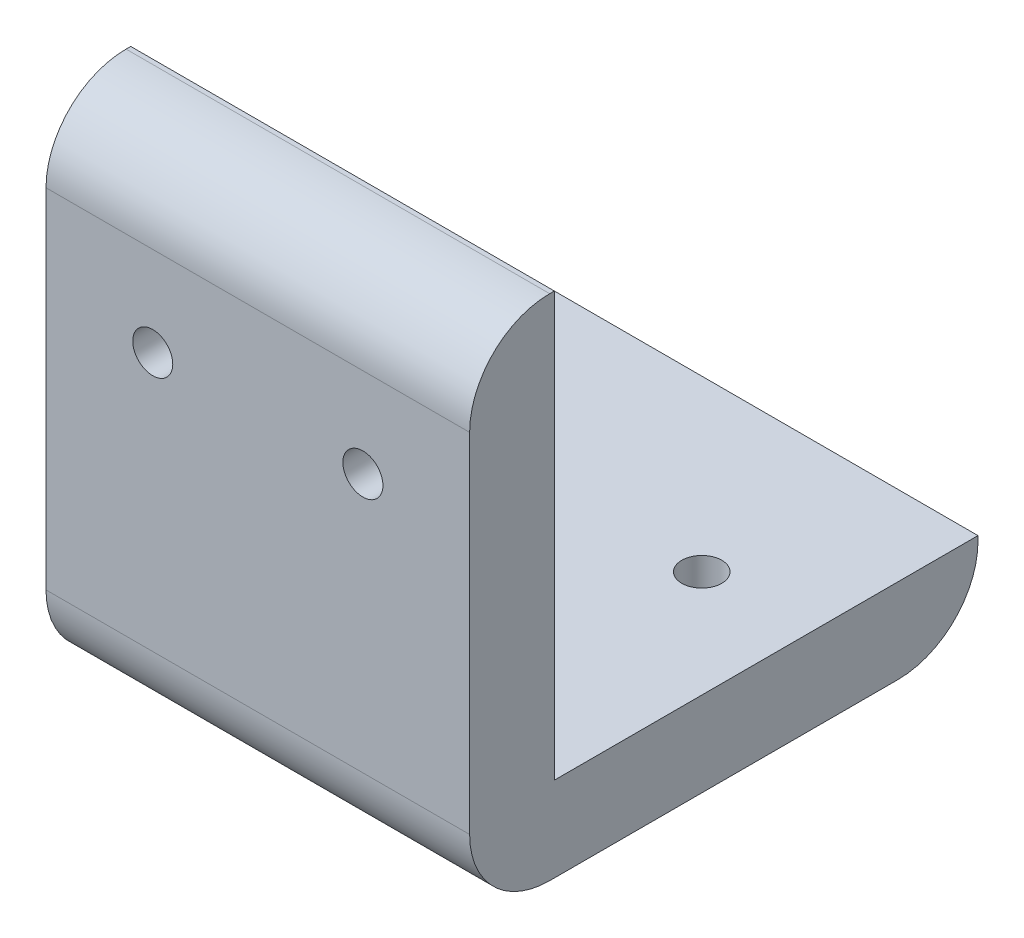
from build123d import *

# Parameters (mm, degrees)
BOSS_EXTRUDE1_DEPTH = 31.75
FILLET1_R           = 6
SKETCH2_R           = 1.5
CUT_EXTRUDE1_DEPTH  = 39.1
SKETCH3_R           = 1.5
CUT_EXTRUDE2_DEPTH  = 39.1
FILLET2_R           = 6


with BuildPart() as part:
    # Sketch1 → Boss-Extrude1 (new body)
    with BuildSketch(Plane(origin=(0, 0, 0), x_dir=(0, 0, -1), z_dir=(1, 0, 0))):
        Polygon((-6.35, 31.75), (-6.35, -6.35), (31.75, -6.35), (31.75, 0), (0, 0), (0, 31.75), align=None)
    extrude(amount=BOSS_EXTRUDE1_DEPTH)

    # Fillet1
    fillet1_edges = [part.edges().sort_by_distance(p)[0] for p in [
        (15.875, -6.35, -31.75),
        (15.875, 31.75, 6.35),
    ]]
    fillet(fillet1_edges, radius=FILLET1_R)

    # Sketch2 → Cut-Extrude1 (cut, through all)
    with BuildSketch(Plane.XY.offset(6.35)):
        with Locations((8, 19.05)):
            Circle(SKETCH2_R)
        with Locations((23.75, 19.05)):
            Circle(SKETCH2_R)
    extrude(amount=-CUT_EXTRUDE1_DEPTH, mode=Mode.SUBTRACT)

    # Sketch3 → Cut-Extrude2 (cut, through all)
    with BuildSketch(Plane.XZ.offset(6.35)):
        with Locations((8, -19.05)):
            Circle(SKETCH3_R)
        with Locations((23.75, -19.05)):
            Circle(SKETCH3_R)
    extrude(amount=-CUT_EXTRUDE2_DEPTH, mode=Mode.SUBTRACT)

    # Fillet2
    fillet2_edges = [part.edges().sort_by_distance(p)[0] for p in [
        (15.875, -6.35, 6.35),
    ]]
    fillet(fillet2_edges, radius=FILLET2_R)


solid = part.part
